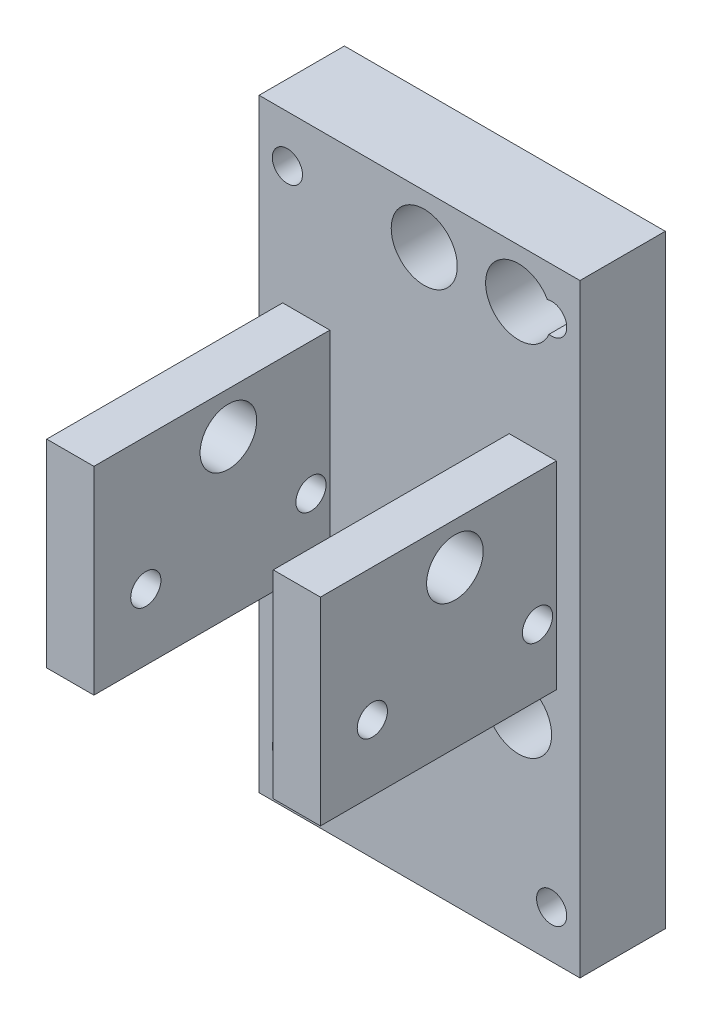
from build123d import *

# Parameters (mm, degrees)
SKETCH1_W           = 34
SKETCH1_H           = 64
BOSS_EXTRUDE1_DEPTH = 9.04
SKETCH2_W           = 5
SKETCH2_H           = 21
BOSS_EXTRUDE2_DEPTH = 25
SKETCH3_R           = 1.6
SKETCH3_R_2         = 3
CUT_EXTRUDE1_DEPTH  = 30
SKETCH4_R           = 1.6
CUT_EXTRUDE2_DEPTH  = 10
SKETCH5_R           = 3.5
CUT_EXTRUDE3_DEPTH  = 10


with BuildPart() as part:
    # Sketch1 → Boss-Extrude1 (new body)
    with BuildSketch(Plane.XY):
        Rectangle(SKETCH1_W, SKETCH1_H)
    extrude(amount=BOSS_EXTRUDE1_DEPTH)

    # Sketch2 → Boss-Extrude2 (add)
    with BuildSketch(Plane.XY.offset(9.04)):
        with Locations((12, 3.7)):
            Rectangle(SKETCH2_W, SKETCH2_H)
        with Locations((-12, 3.7)):
            Rectangle(SKETCH2_W, SKETCH2_H)
    extrude(amount=BOSS_EXTRUDE2_DEPTH)

    # Sketch3 → Cut-Extrude1 (cut)
    with BuildSketch(Plane(origin=(14.5, 0, 0), x_dir=(0, 0, -1), z_dir=(1, 0, 0))):
        with Locations((-28.54, 0.2)):
            Circle(SKETCH3_R)
        with Locations((-11.04, 0.2)):
            Circle(SKETCH3_R)
        with Locations((-19.79, 9.8)):
            Circle(SKETCH3_R_2)
    extrude(amount=-CUT_EXTRUDE1_DEPTH, mode=Mode.SUBTRACT)

    # Sketch4 → Cut-Extrude2 (cut)
    with BuildSketch(Plane.XY.offset(9.04)):
        with Locations((-14, -27)):
            Circle(SKETCH4_R)
        with Locations((-14, 27)):
            Circle(SKETCH4_R)
        with Locations((14, -27)):
            Circle(SKETCH4_R)
        with Locations((14, 27)):
            Circle(SKETCH4_R)
    extrude(amount=-CUT_EXTRUDE2_DEPTH, mode=Mode.SUBTRACT)

    # Sketch5 → Cut-Extrude3 (cut)
    with BuildSketch(Plane(origin=(0, 0, 0), x_dir=(-1, 0, 0), z_dir=(0, 0, -1))):
        with Locations((-0.5, 26.8)):
            Circle(SKETCH5_R)
        with Locations((-10.5, 26.8)):
            Circle(SKETCH5_R)
        with Locations((-0.5, -11.2)):
            Circle(SKETCH5_R)
        with Locations((-10.5, -11.2)):
            Circle(SKETCH5_R)
    extrude(amount=-CUT_EXTRUDE3_DEPTH, mode=Mode.SUBTRACT)


solid = part.part
